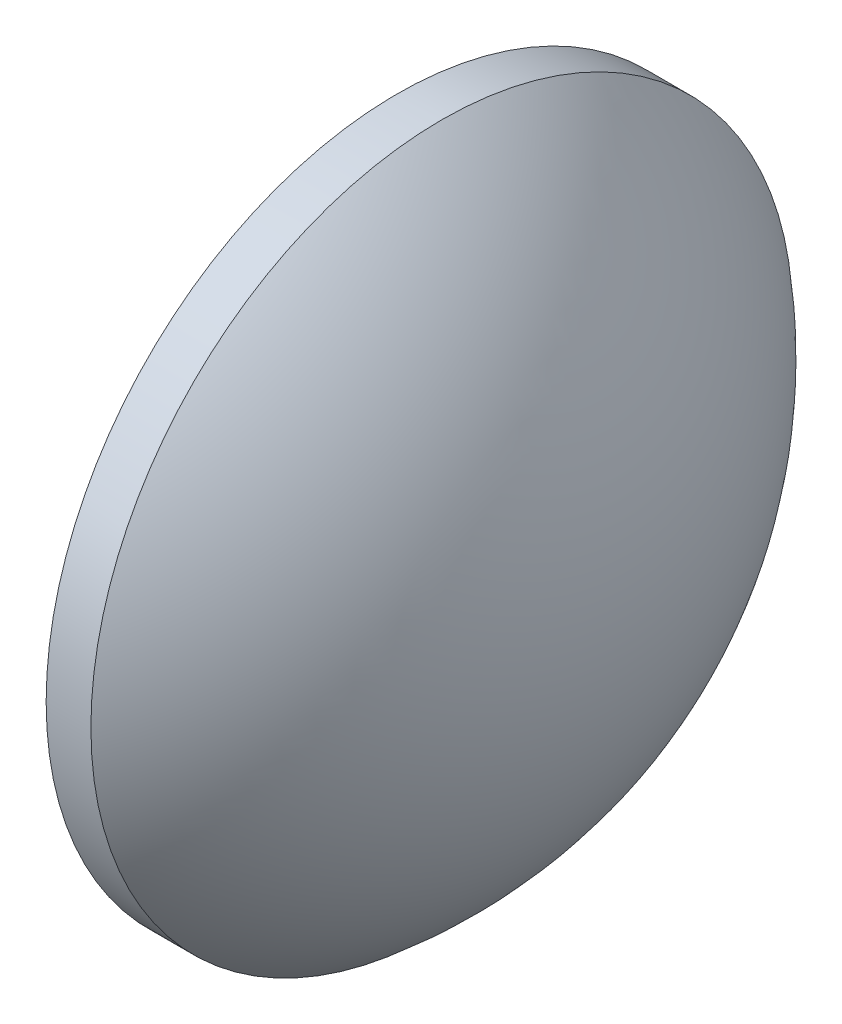
from build123d import *


with BuildPart() as part:
    # 草图1 → 旋转1 (revolve)
    with BuildSketch(Plane.XY):
        with BuildLine():
            Line((350.77819975, 126.800050535), (350.77819975, 134.800050535))
            Line((350.77819975, 134.800050535), (351.79819975, 134.800050535))
            ThreePointArc((351.79819975, 134.800050535), (354.585631746, 131.224087153), (355.57819975, 126.800050535))
            Line((355.57819975, 126.800050535), (350.77819975, 126.800050535))
        make_face()
    revolve(axis=Axis((332.151856648, 126.800050535, 0), (1, 0, 0)))


solid = part.part
